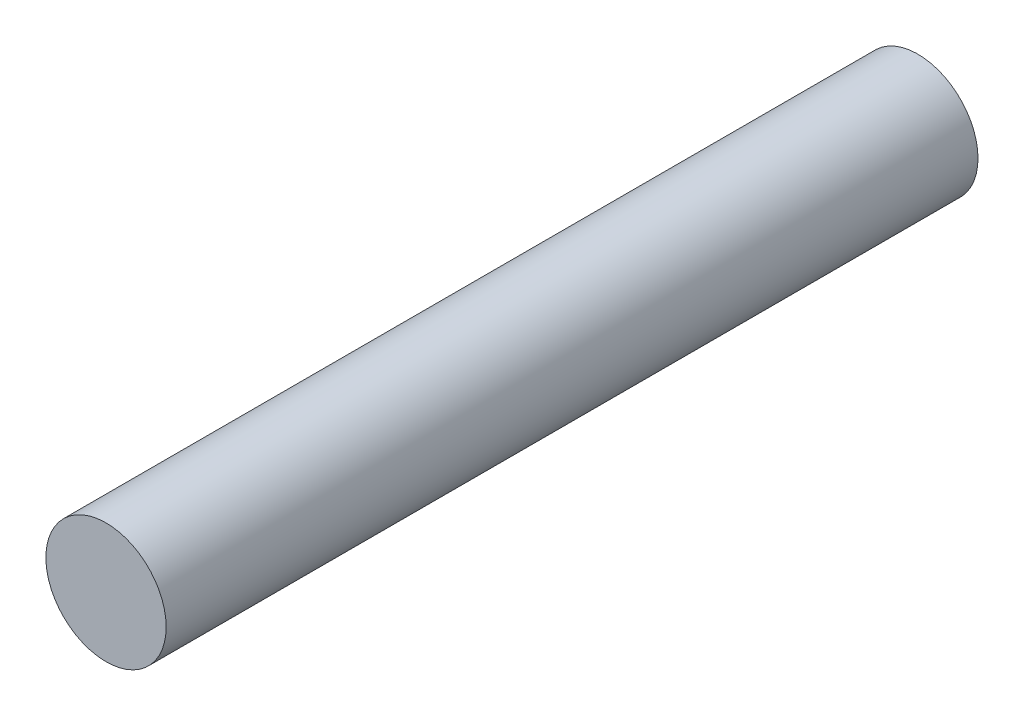
from build123d import *

# Parameters (mm, degrees)
SKETCH_1_R      = 1
EXTRUDE_1_DEPTH = 13.5


with BuildPart() as part:
    # 草图1 → 凸台-拉伸1 (new body)
    with BuildSketch(Plane.XY):
        Circle(SKETCH_1_R)
    extrude(amount=EXTRUDE_1_DEPTH)


solid = part.part
